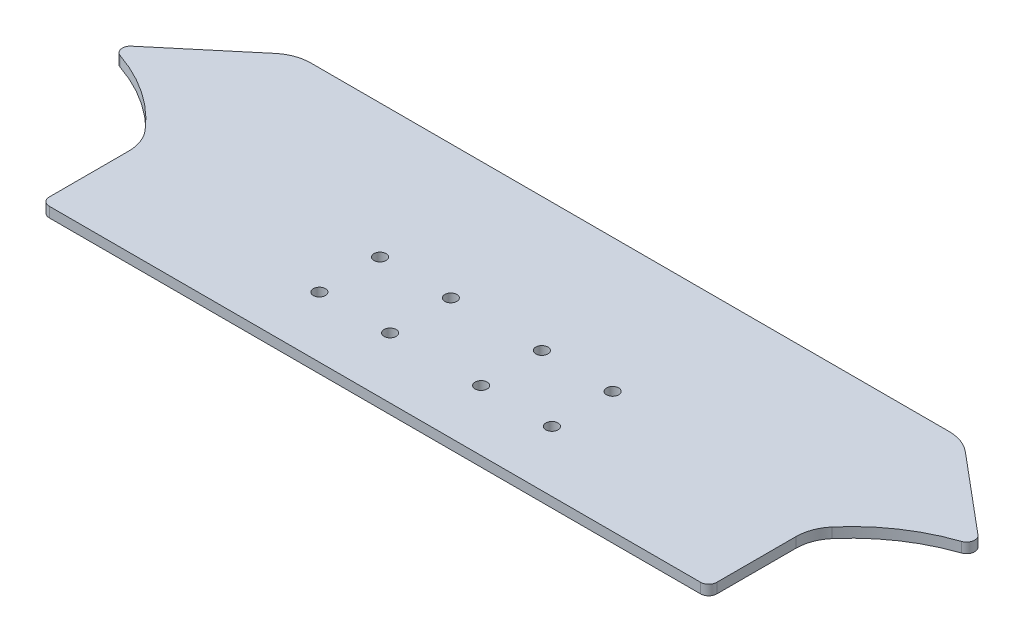
from build123d import *

# Parameters (mm, degrees)
SKETCH1_W           = 209.55
SKETCH1_H           = 80.01
BOSS_EXTRUDE1_DEPTH = 3.175
BOSS_EXTRUDE2_DEPTH = 3.175
SKETCH3_R           = 1.89865
CUT_EXTRUDE1_DEPTH  = 4.175
FILLET1_R           = 12.7
FILLET3_R           = 2.54
FILLET4_R           = 12.7


with BuildPart() as part:
    # Sketch1 → Boss-Extrude1 (new body)
    with BuildSketch(Plane(origin=(0, 0, 0), x_dir=(1, 0, 0), z_dir=(0, 1, 0))):
        Rectangle(SKETCH1_W, SKETCH1_H)
    extrude(amount=BOSS_EXTRUDE1_DEPTH)

    # Sketch2 → Boss-Extrude2 (add, through all)
    with BuildSketch(Plane(origin=(0, 3.175, 0), x_dir=(1, 0, 0), z_dir=(0, 1, 0))):
        with BuildLine():
            Line((104.775, 40.005), (136.525, 13.36358671))
            ThreePointArc((136.525, 13.36358671), (118.699650285, 5.41866207), (104.775, -8.255))
            Line((104.775, -8.255), (104.775, 40.005))
        make_face()
        with BuildLine():
            Line((-104.775, 40.005), (-136.525, 13.36358671))
            ThreePointArc((-136.525, 13.36358671), (-118.699650285, 5.41866207), (-104.775, -8.255))
            Line((-104.775, -8.255), (-104.775, 40.005))
        make_face()
    extrude(amount=-BOSS_EXTRUDE2_DEPTH)

    # Sketch3 → Cut-Extrude1 (cut, through all)
    with BuildSketch(Plane(origin=(0, 3.175, 0), x_dir=(1, 0, 0), z_dir=(0, 1, 0))):
        with Locations((36.5125, -20.955)):
            Circle(SKETCH3_R)
        with Locations((14.2875, -20.955)):
            Circle(SKETCH3_R)
        with Locations((-14.2875, -20.955)):
            Circle(SKETCH3_R)
        with Locations((-36.5125, -20.955)):
            Circle(SKETCH3_R)
        with Locations((36.5125, -1.905)):
            Circle(SKETCH3_R)
        with Locations((14.2875, -1.905)):
            Circle(SKETCH3_R)
        with Locations((-14.2875, -1.905)):
            Circle(SKETCH3_R)
        with Locations((-36.5125, -1.905)):
            Circle(SKETCH3_R)
    extrude(amount=-CUT_EXTRUDE1_DEPTH, mode=Mode.SUBTRACT)

    # Fillet1
    fillet1_edges = [part.edges().sort_by_distance(p)[0] for p in [
        (104.775, 1.5875, 8.255),
        (-104.775, 1.5875, 8.255),
    ]]
    fillet(fillet1_edges, radius=FILLET1_R)

    # Fillet3
    fillet3_edges = [part.edges().sort_by_distance(p)[0] for p in [
        (136.525, 1.5875, -13.36358671),
        (-136.525, 1.5875, -13.36358671),
        (104.775, 1.5875, 40.005),
        (-104.775, 1.5875, 40.005),
    ]]
    fillet(fillet3_edges, radius=FILLET3_R)

    # Fillet4
    fillet4_edges = [part.edges().sort_by_distance(p)[0] for p in [
        (-104.775, 1.5875, -40.005),
        (104.775, 1.5875, -40.005),
    ]]
    fillet(fillet4_edges, radius=FILLET4_R)


solid = part.part
